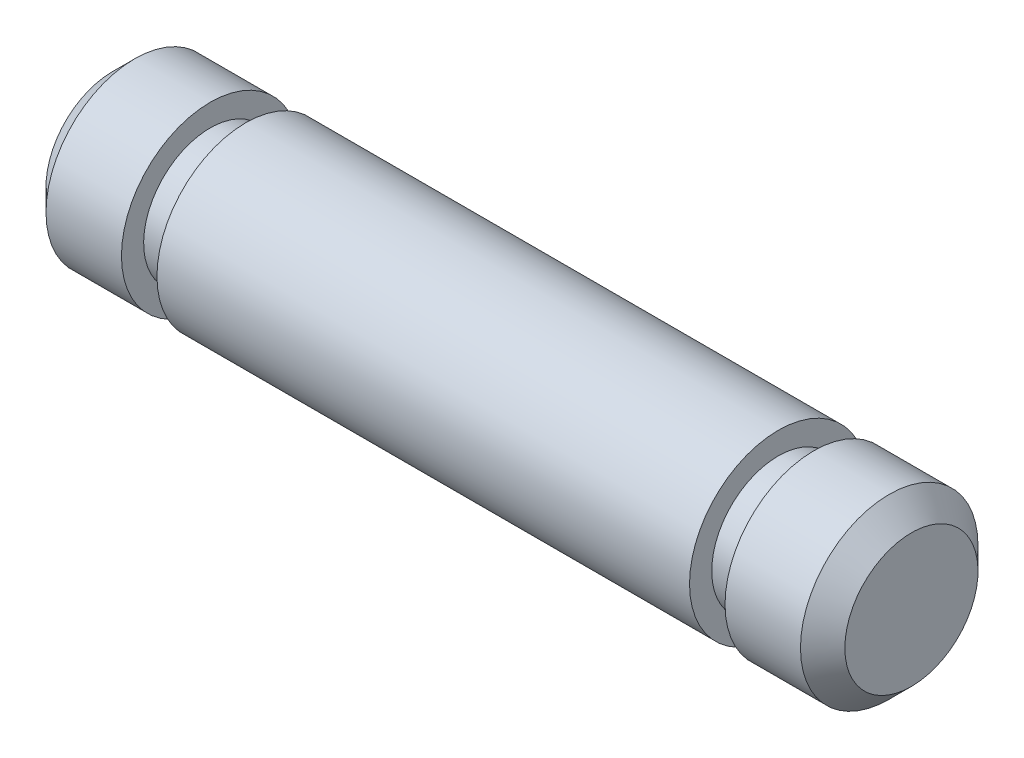
from build123d import *

# Parameters (mm, degrees)
SKETCH1_W          = 18
SKETCH1_H          = 2
CUT_EXTRUDE1_START = -3
SKETCH2_R          = 2
SKETCH2_R_2        = 1.5
CUT_EXTRUDE1_DEPTH = 0.8
CUT_EXTRUDE2_START = -3
SKETCH4_R          = 2
SKETCH4_R_2        = 1.5
CUT_EXTRUDE2_DEPTH = 0.8
CHAMFER1_SIZE      = 0.5


with BuildPart() as part:
    # Sketch1 → Revolve1 (revolve)
    with BuildSketch(Plane.XY):
        with Locations((9, 1)):
            Rectangle(SKETCH1_W, SKETCH1_H)
    revolve(axis=Axis((18, 2, 0), (-1, 0, 0)))

    # Sketch2 → Cut-Extrude1 (cut)
    with BuildSketch(Plane.ZY.offset(CUT_EXTRUDE1_START)):
        with Locations((0, 2)):
            Circle(SKETCH2_R)
        with Locations((0, 2)):
            Circle(SKETCH2_R_2, mode=Mode.SUBTRACT)
    extrude(amount=CUT_EXTRUDE1_DEPTH, mode=Mode.SUBTRACT)

    # Sketch4 → Cut-Extrude2 (cut)
    with BuildSketch(Plane(origin=(18, 0, 0), x_dir=(0, 0, -1), z_dir=(1, 0, 0)).offset(CUT_EXTRUDE2_START)):
        with Locations((0, 2)):
            Circle(SKETCH4_R)
        with Locations((0, 2)):
            Circle(SKETCH4_R_2, mode=Mode.SUBTRACT)
    extrude(amount=CUT_EXTRUDE2_DEPTH, mode=Mode.SUBTRACT)

    # Chamfer1
    chamfer1_edges = [part.edges().sort_by_distance(p)[0] for p in [
        (18, 4, 0),
        (0, 4, 0),
    ]]
    chamfer(chamfer1_edges, length=CHAMFER1_SIZE)


solid = part.part
